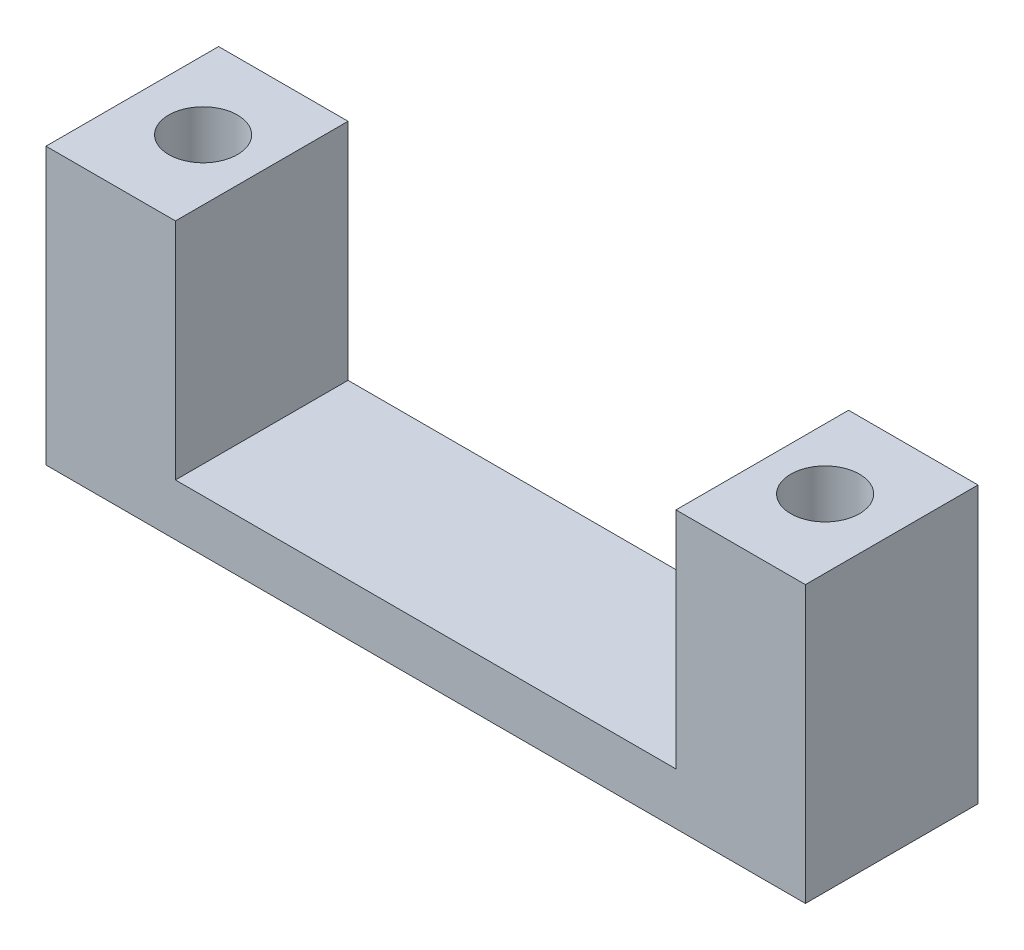
from build123d import *

# Parameters (mm, degrees)
SKETCH1_W                      = 55.88
SKETCH1_H                      = 12.7
BOSS_EXTRUDE1_DEPTH            = 3.81
SKETCH2_W                      = 9.525
SKETCH2_H                      = 12.7
BOSS_EXTRUDE2_DEPTH            = 16.51
F_8_0_199_DIAMETER_HOLE1_D     = 5.0546
F_8_0_199_DIAMETER_HOLE1_DEPTH = 7.112
F_8_0_199_DIAMETER_HOLE1_TIP   = 1.518555042


with BuildPart() as part:
    # Sketch1 → Boss-Extrude1 (new body)
    with BuildSketch(Plane(origin=(0, 0, 0), x_dir=(1, 0, 0), z_dir=(0, 1, 0))):
        with Locations((-27.94, 6.35)):
            Rectangle(SKETCH1_W, SKETCH1_H)
    extrude(amount=BOSS_EXTRUDE1_DEPTH)

    # Sketch2 → Boss-Extrude2 (add)
    with BuildSketch(Plane(origin=(0, 3.81, 0), x_dir=(1, 0, 0), z_dir=(0, 1, 0))):
        with Locations((-51.1175, 6.35)):
            Rectangle(SKETCH2_W, SKETCH2_H)
        with Locations((-4.7625, 6.35)):
            Rectangle(SKETCH2_W, SKETCH2_H)
    extrude(amount=BOSS_EXTRUDE2_DEPTH)

    # #8 (0.199) Diameter Hole1
    with Locations(Plane(origin=(0, 20.32, 0), x_dir=(1, 0, 0), z_dir=(0, 1, 0))):
        with Locations((-50.8254, 6.505248616), (-5.0546, 6.505248616)):
            Hole(F_8_0_199_DIAMETER_HOLE1_D / 2, depth=F_8_0_199_DIAMETER_HOLE1_DEPTH)
            with Locations((0, 0, -(F_8_0_199_DIAMETER_HOLE1_DEPTH + F_8_0_199_DIAMETER_HOLE1_TIP / 2))):  # 118° drill point
                Cone(0, F_8_0_199_DIAMETER_HOLE1_D / 2, F_8_0_199_DIAMETER_HOLE1_TIP, mode=Mode.SUBTRACT)


solid = part.part
